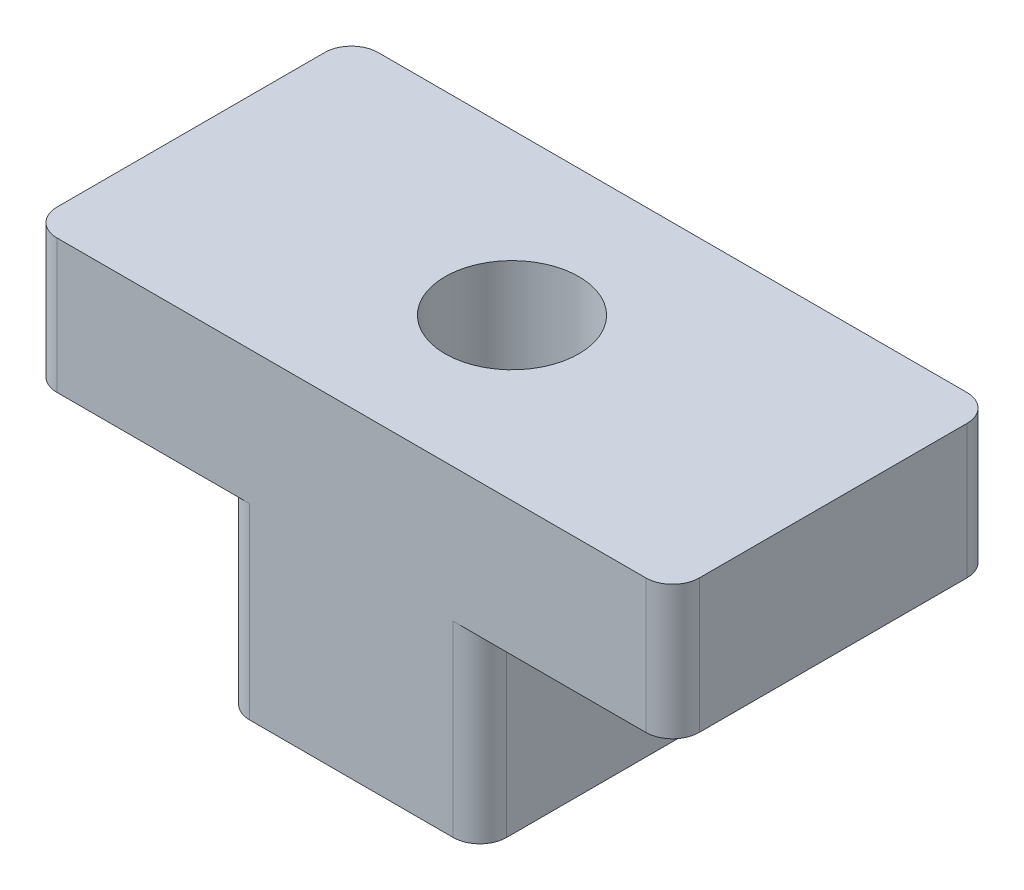
from build123d import *

# Parameters (mm, degrees)
BOSS_EXTRU_1_DEPTH      = 3
ESQUISSE2_R             = 1.25
ENL_V_MAT_EXTRU_1_DEPTH = 7
CONG_2_R                = 0.5


with BuildPart() as part:
    # Esquisse1 → Boss.-Extru.1 (new body, symmetric)
    with BuildSketch(Plane.XY):
        Polygon((-6, 0), (-2.4, 0), (-2.4, -3.5), (2.4, -3.5), (2.4, 0), (6, 0), (6, 2.5), (-6, 2.5), align=None)
    extrude(amount=BOSS_EXTRU_1_DEPTH, both=True)

    # Esquisse2 → Enlèv. mat.-Extru.1 (cut, through all)
    with BuildSketch(Plane(origin=(0, 2.5, 0), x_dir=(1, 0, 0), z_dir=(0, 1, 0))):
        Circle(ESQUISSE2_R)
    extrude(amount=-ENL_V_MAT_EXTRU_1_DEPTH, mode=Mode.SUBTRACT)

    # Congé2
    cong_2_edges = [part.edges().sort_by_distance(p)[0] for p in [
        (-6, 1.25, -3),
        (6, 1.25, -3),
        (-6, 1.25, 3),
        (-2.4, -1.75, 3),
        (2.4, -1.75, 3),
        (6, 1.25, 3),
        (2.4, -1.75, -3),
        (-2.4, -1.75, -3),
    ]]
    fillet(cong_2_edges, radius=CONG_2_R)


solid = part.part
